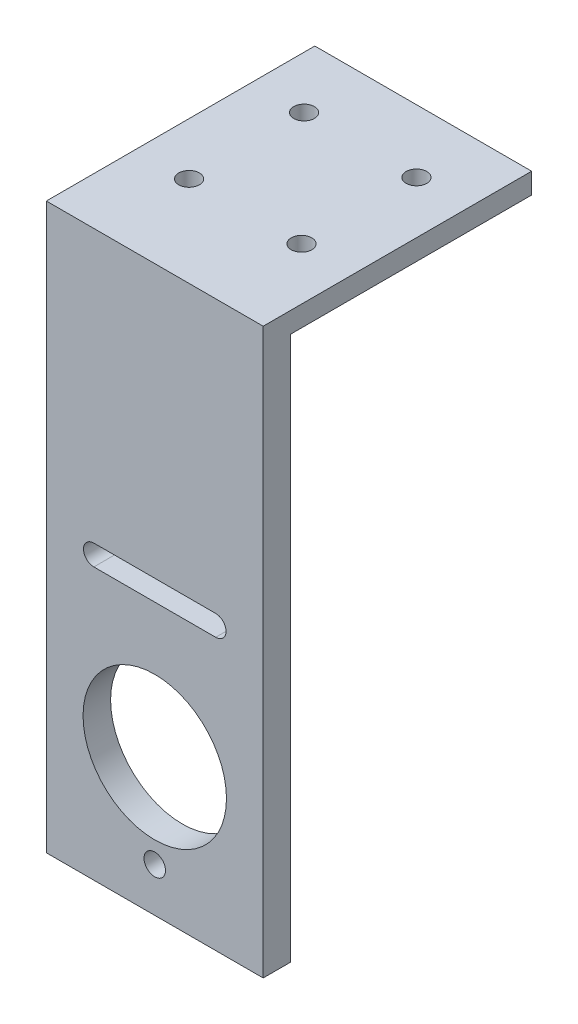
from build123d import *

# Parameters (mm, degrees)
SKETCH_1_W          = 31.500863908
SKETCH_1_H          = 82
SKETCH_1_R          = 10.417524335
SKETCH_1_R_2        = 1.56
EXTRUDE_1_DEPTH     = 4
SKETCH_3_W          = 31.500863908
SKETCH_3_H          = 3
EXTRUDE_2_DEPTH     = 35
SKETCH_6_R          = 1.5
CUT_EXTRUDE_1_DEPTH = 4


with BuildPart() as part:
    # 草图1 → 凸台-拉伸1 (new body)
    with BuildSketch(Plane.XY):
        with Locations((0, 14.377078694)):
            Rectangle(SKETCH_1_W, SKETCH_1_H)
        with Locations((0, -6.708333333)):
            Circle(SKETCH_1_R, mode=Mode.SUBTRACT)
        with Locations((0, -20.208333333)):
            Circle(SKETCH_1_R_2, mode=Mode.SUBTRACT)
        with BuildLine():
            Line((8.85, 15.791666667), (-8.85, 15.791666667))
            ThreePointArc((-8.85, 15.791666667), (-10.35, 14.291666667), (-8.85, 12.791666667))
            Line((-8.85, 12.791666667), (8.85, 12.791666667))
            ThreePointArc((8.85, 12.791666667), (10.35, 14.291666667), (8.85, 15.791666667))
        make_face(mode=Mode.SUBTRACT)
    extrude(amount=EXTRUDE_1_DEPTH)

    # 草图3 → 凸台-拉伸2 (add)
    with BuildSketch(Plane(origin=(0, 0, 0), x_dir=(-1, 0, 0), z_dir=(0, 0, -1))):
        with Locations((0, 53.877078694)):
            Rectangle(SKETCH_3_W, SKETCH_3_H)
    extrude(amount=EXTRUDE_2_DEPTH)

    # 草图6 → 切除-拉伸1 (cut, through all)
    with BuildSketch(Plane.XZ.offset(-52.377078694)):
        with Locations((-8.166436246, -9.151254402)):
            Circle(SKETCH_6_R)
        with Locations((8.166436246, -9.151254402)):
            Circle(SKETCH_6_R)
        with Locations((8.166436246, -25.848745598)):
            Circle(SKETCH_6_R)
        with Locations((-8.166436246, -25.848745598)):
            Circle(SKETCH_6_R)
    extrude(amount=-CUT_EXTRUDE_1_DEPTH, mode=Mode.SUBTRACT)


solid = part.part
